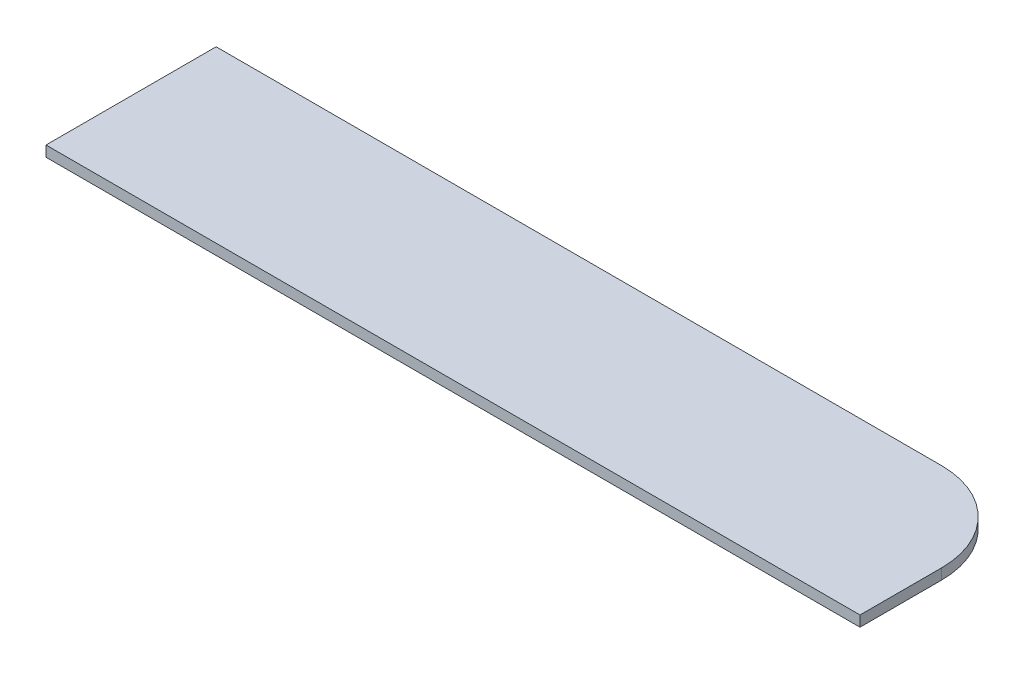
from build123d import *

# Parameters (mm, degrees)
BOSS_EXTRUDE1_DEPTH = 18


with BuildPart() as part:
    # Sketch1 → Boss-Extrude1 (new body)
    with BuildSketch(Plane(origin=(0, 0, 0), x_dir=(1, 0, 0), z_dir=(0, 1, 0))):
        with BuildLine():
            Line((689, -144), (-689, -144))
            Line((-689, -144), (-689, 144))
            Line((-689, 144), (539, 144))
            ThreePointArc((539, 144), (645.066017178, 100.066017178), (689, -6))
            Line((689, -6), (689, -144))
        make_face()
    extrude(amount=BOSS_EXTRUDE1_DEPTH)


solid = part.part
